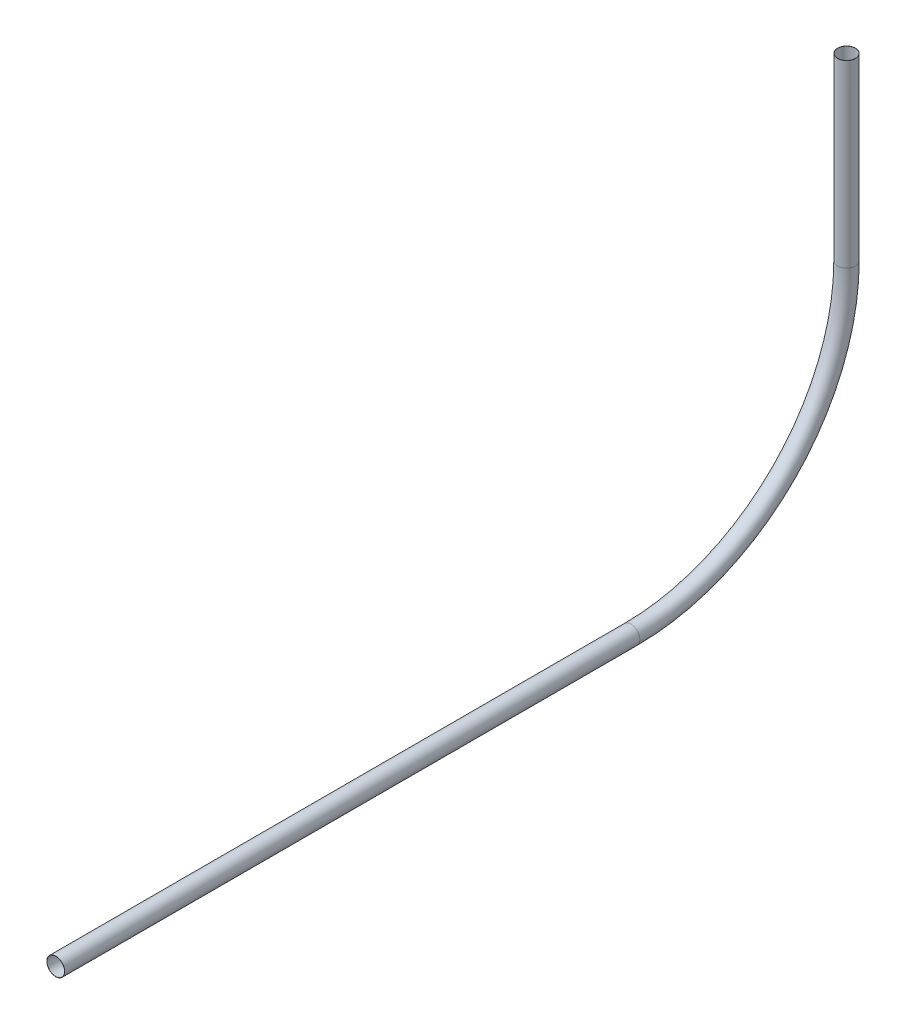
from build123d import *

# Parameters (mm, degrees)
SKETCH1_R   = 1.5875
SKETCH1_R_2 = 1.5494


with BuildPart() as part:
    # Sweep1: sweep along a path in Sketch2
    with BuildLine(Plane(origin=(0, 0, 0), x_dir=(0, 0, -1), z_dir=(1, 0, 0))) as sweep1_path:
        Line((0, 0), (0, -31.75))
        ThreePointArc((0, -31.75), (-11.159231637, -58.690768363), (-38.1, -69.85))
        Line((-38.1, -69.85), (-139.7, -69.85))
    # Sketch1 → Sweep1 (sweep)
    with BuildSketch(Plane(origin=(0, 0, 0), x_dir=(1, 0, 0), z_dir=(0, 1, 0))):
        Circle(SKETCH1_R)
        Circle(SKETCH1_R_2, mode=Mode.SUBTRACT)
    sweep(path=sweep1_path.line)


solid = part.part
